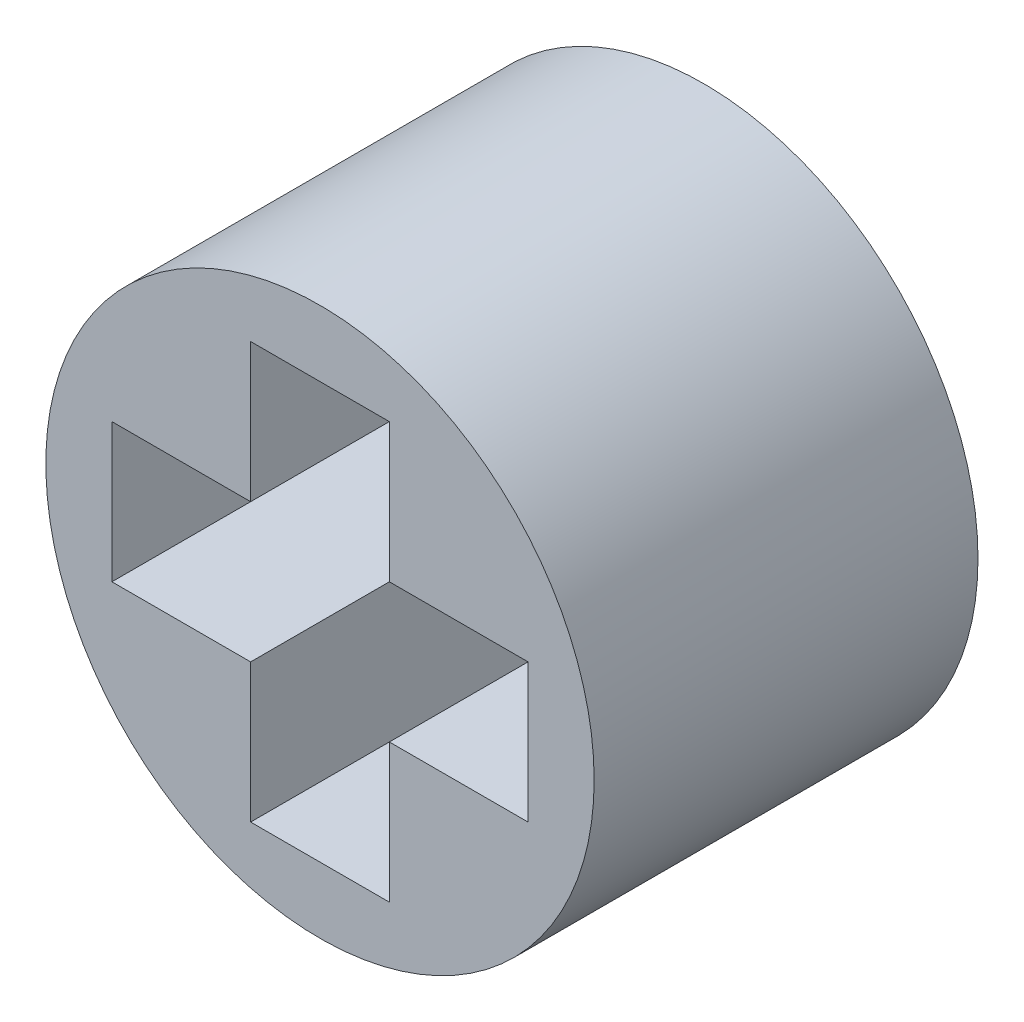
from build123d import *

# Parameters (mm, degrees)
SKETCH1_R           = 5
BOSS_EXTRUDE1_DEPTH = 7


with BuildPart() as part:
    # Sketch1 → Boss-Extrude1 (new body)
    with BuildSketch(Plane.XY):
        Circle(SKETCH1_R)
        Polygon((-3.794733192, 1.264911064), (-3.794733192, -1.264911064), (-1.264911064, -1.264911064), (-1.264911064, -3.794733192), (1.264911064, -3.794733192), (1.264911064, -1.264911064), (3.794733192, -1.264911064), (3.794733192, 1.264911064), (1.264911064, 1.264911064), (1.264911064, 3.794733192), (-1.264911064, 3.794733192), (-1.264911064, 1.264911064), align=None, mode=Mode.SUBTRACT)
    extrude(amount=BOSS_EXTRUDE1_DEPTH)


solid = part.part
